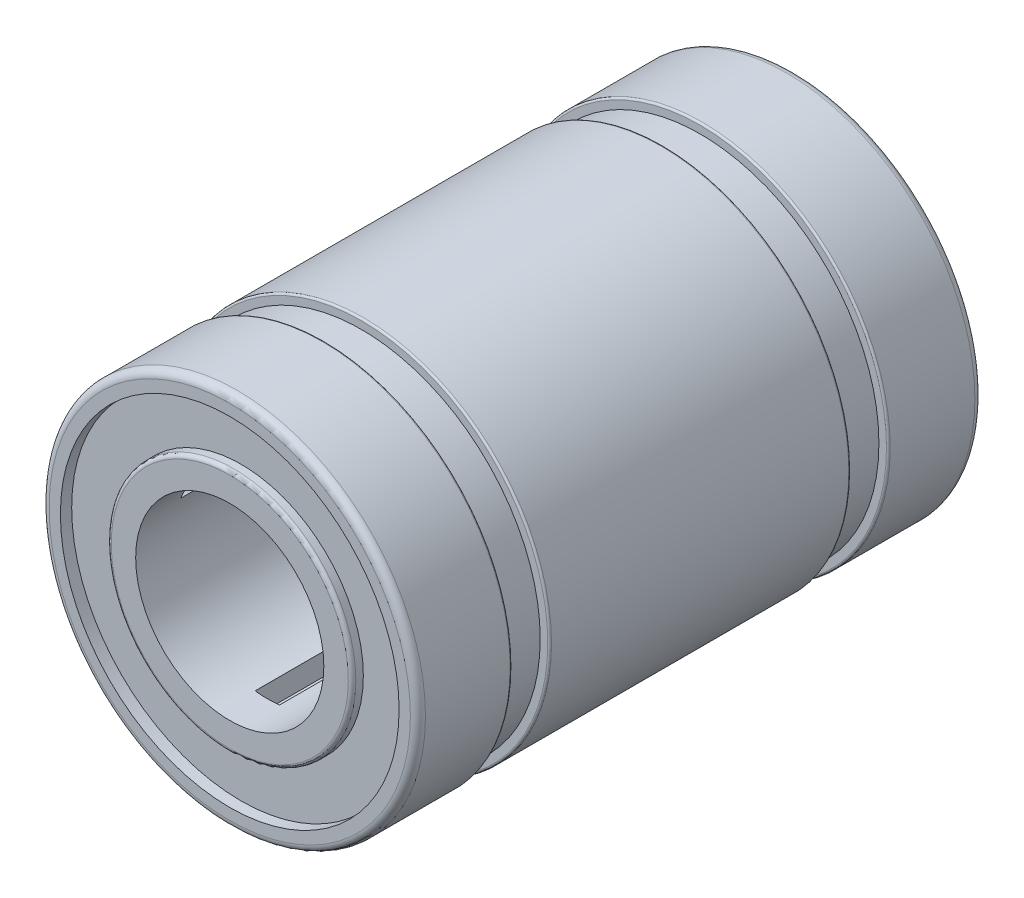
from build123d import *

# Parameters (mm, degrees)
SKETCH1_R                = 5
BOSS_EXTRUDE1_DEPTH      = 4
BOSS_EXTRUDE1_DEPTH_BACK = 4
SKETCH2_R                = 4.75
BOSS_EXTRUDE2_DEPTH      = 1
BOSS_EXTRUDE2_DEPTH_BACK = 9
SKETCH3_R                = 5
BOSS_EXTRUDE3_DEPTH      = 2.5
SKETCH4_R                = 5
BOSS_EXTRUDE4_DEPTH      = 2.5
SKETCH5_R                = 4.5
CUT_EXTRUDE1_DEPTH       = 0.3
SKETCH6_R                = 4.5
CUT_EXTRUDE2_DEPTH       = 0.3
SKETCH7_R                = 3.25
BOSS_EXTRUDE5_DEPTH      = 0.3
SKETCH8_R                = 3.25
BOSS_EXTRUDE6_DEPTH      = 0.3
SKETCH9_R                = 2.5
CUT_EXTRUDE3_DEPTH       = 20.3
SKETCH10_W               = 0.64983534
SKETCH10_H               = 1.129620884
CUT_EXTRUDE4_DEPTH       = 14
SKETCH11_R               = 3.25
SKETCH11_R_2             = 2.5
BOSS_EXTRUDE7_DEPTH      = 1
FILLET1_R                = 0.2
FILLET2_R                = 0.05
FILLET3_R                = 0.1


with BuildPart() as part:
    # Sketch1 → Boss-Extrude1 (new body, two sides)
    with BuildSketch(Plane.XY) as boss_extrude1_sk:
        Circle(SKETCH1_R)
    extrude(amount=BOSS_EXTRUDE1_DEPTH)
    extrude(boss_extrude1_sk.sketch, amount=-BOSS_EXTRUDE1_DEPTH_BACK)

    # Sketch2 → Boss-Extrude2 (add, two sides)
    with BuildSketch(Plane.XY.offset(4)) as boss_extrude2_sk:
        Circle(SKETCH2_R)
    extrude(amount=BOSS_EXTRUDE2_DEPTH)
    extrude(boss_extrude2_sk.sketch, amount=-BOSS_EXTRUDE2_DEPTH_BACK)

    # Sketch3 → Boss-Extrude3 (add)
    with BuildSketch(Plane.XY.offset(5)):
        Circle(SKETCH3_R)
    extrude(amount=BOSS_EXTRUDE3_DEPTH)

    # Sketch4 → Boss-Extrude4 (add)
    with BuildSketch(Plane(origin=(0, 0, -5), x_dir=(-1, 0, 0), z_dir=(0, 0, -1))):
        Circle(SKETCH4_R)
    extrude(amount=BOSS_EXTRUDE4_DEPTH)

    # Sketch5 → Cut-Extrude1 (cut)
    with BuildSketch(Plane.XY.offset(7.5)):
        Circle(SKETCH5_R)
    extrude(amount=-CUT_EXTRUDE1_DEPTH, mode=Mode.SUBTRACT)

    # Sketch6 → Cut-Extrude2 (cut)
    with BuildSketch(Plane(origin=(0, 0, -7.5), x_dir=(-1, 0, 0), z_dir=(0, 0, -1))):
        Circle(SKETCH6_R)
    extrude(amount=-CUT_EXTRUDE2_DEPTH, mode=Mode.SUBTRACT)

    # Sketch7 → Boss-Extrude5 (add)
    with BuildSketch(Plane(origin=(0, 0, -7.2), x_dir=(-1, 0, 0), z_dir=(0, 0, -1))):
        Circle(SKETCH7_R)
    extrude(amount=BOSS_EXTRUDE5_DEPTH)

    # Sketch8 → Boss-Extrude6 (add)
    with BuildSketch(Plane.XY.offset(7.2)):
        Circle(SKETCH8_R)
    extrude(amount=BOSS_EXTRUDE6_DEPTH)

    # Sketch9 → Cut-Extrude3 (cut)
    with BuildSketch(Plane(origin=(0, 0, -7.5), x_dir=(-1, 0, 0), z_dir=(0, 0, -1))):
        Circle(SKETCH9_R)
    extrude(amount=-CUT_EXTRUDE3_DEPTH, mode=Mode.SUBTRACT)

    # Sketch10 → Cut-Extrude4 (cut)
    with BuildSketch(Plane(origin=(0, 0, -7.5), x_dir=(-1, 0, 0), z_dir=(0, 0, -1))):
        with Locations((0, -2.5)):
            Rectangle(SKETCH10_W, SKETCH10_H)
        Polygon((-1.513464483, 1.248981736), (-2.491744865, 1.813792177), (-2.816662536, 1.251018264), (-1.838382154, 0.686207823), align=None)
        Polygon((1.838382154, 0.686207823), (2.816662536, 1.251018264), (2.491744865, 1.813792177), (1.513464483, 1.248981736), align=None)
    extrude(amount=-CUT_EXTRUDE4_DEPTH, mode=Mode.SUBTRACT)

    # Sketch11 → Boss-Extrude7 (add)
    with BuildSketch(Plane(origin=(0, 0, -7.5), x_dir=(-1, 0, 0), z_dir=(0, 0, -1))):
        Circle(SKETCH11_R)
        Circle(SKETCH11_R_2, mode=Mode.SUBTRACT)
    extrude(amount=-BOSS_EXTRUDE7_DEPTH)

    # Fillet1
    fillet1_edges = [part.edges().sort_by_distance(p)[0] for p in [
        (-5, 0, 7.5),
        (5, 0, -7.5),
    ]]
    fillet(fillet1_edges, radius=FILLET1_R)

    # Fillet2
    fillet2_edges = [part.edges().sort_by_distance(p)[0] for p in [
        (-5, 0, 5),
        (5, 0, -5),
        (-5, 0, -4),
        (-5, 0, 4),
    ]]
    fillet(fillet2_edges, radius=FILLET2_R)

    # Fillet3
    fillet3_edges = [part.edges().sort_by_distance(p)[0] for p in [
        (3.25, 0, -7.5),
        (-3.25, 0, 7.5),
    ]]
    fillet(fillet3_edges, radius=FILLET3_R)


solid = part.part
